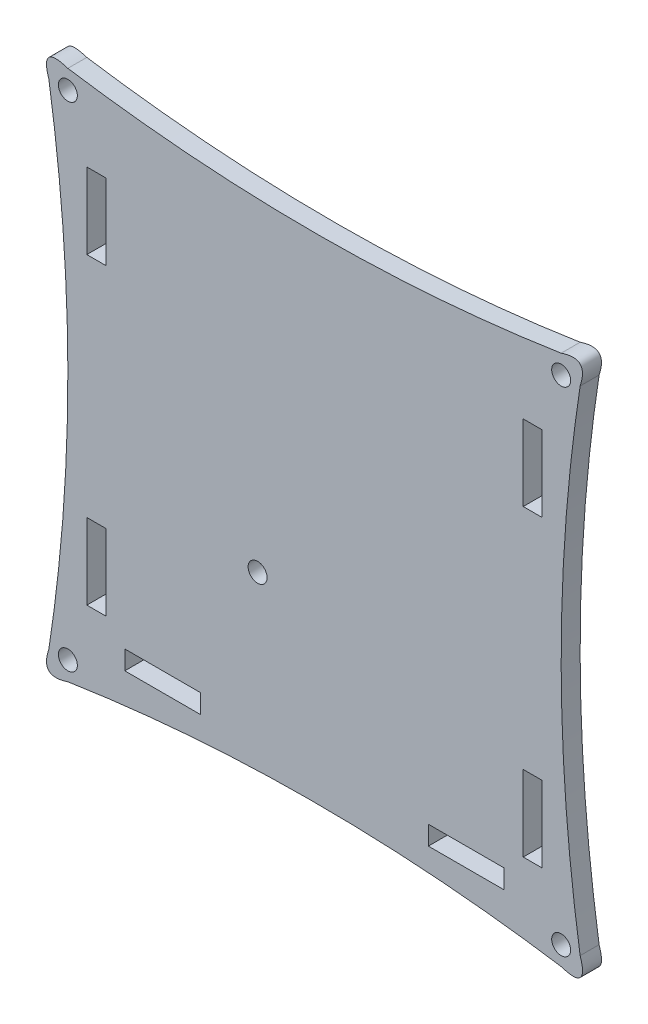
from build123d import *

# Parameters (mm, degrees)
SKETCH1_W           = 6.35
SKETCH1_H           = 25.4
SKETCH1_W_2         = 25.4
SKETCH1_H_2         = 6.35
BOSS_EXTRUDE1_DEPTH = 6.35
SKETCH2_R           = 3.175
CUT_EXTRUDE1_DEPTH  = 6.35
SKETCH3_R           = 3.175
CUT_EXTRUDE2_DEPTH  = 6.35


with BuildPart() as part:
    # Sketch1 → Boss-Extrude1 (new body)
    with BuildSketch(Plane.XY):
        with BuildLine():
            add(Edge.make_bspline(
                [(0, 171.45), (12.7, 88.9), (0, 6.35)],
                knots=[0, 0, 0, 1, 1, 1], degree=2))
            add(Edge.make_bspline(
                [(0, 6.35), (-3.175, -3.175), (6.35, 0)],
                knots=[0, 0, 0, 1, 1, 1], degree=2))
            add(Edge.make_bspline(
                [(6.35, 0), (88.9, 12.7), (171.45, 0)],
                knots=[0, 0, 0, 1, 1, 1], degree=2))
            add(Edge.make_bspline(
                [(177.8, 6.35), (180.975, -3.175), (171.45, 0)],
                knots=[0, 0, 0, 1, 1, 1], degree=2))
            add(Edge.make_bspline(
                [(177.8, 171.45), (165.1, 88.9), (177.8, 6.35)],
                knots=[0, 0, 0, 1, 1, 1], degree=2))
            add(Edge.make_bspline(
                [(171.45, 177.8), (180.975, 180.975), (177.8, 171.45)],
                knots=[0, 0, 0, 1, 1, 1], degree=2))
            add(Edge.make_bspline(
                [(6.35, 177.8), (88.9, 165.1), (171.45, 177.8)],
                knots=[0, 0, 0, 1, 1, 1], degree=2))
            add(Edge.make_bspline(
                [(0, 171.45), (-3.175, 180.975), (6.35, 177.8)],
                knots=[0, 0, 0, 1, 1, 1], degree=2))
        make_face()
        with Locations((15.875, 38.1)):
            Rectangle(SKETCH1_W, SKETCH1_H, mode=Mode.SUBTRACT)
        with Locations((38.1, 15.875)):
            Rectangle(SKETCH1_W_2, SKETCH1_H_2, mode=Mode.SUBTRACT)
        with Locations((15.875, 139.7)):
            Rectangle(SKETCH1_W, SKETCH1_H, mode=Mode.SUBTRACT)
        with Locations((161.925, 139.7)):
            Rectangle(SKETCH1_W, SKETCH1_H, mode=Mode.SUBTRACT)
        with Locations((139.7, 15.875)):
            Rectangle(SKETCH1_W_2, SKETCH1_H_2, mode=Mode.SUBTRACT)
        with Locations((161.925, 38.1)):
            Rectangle(SKETCH1_W, SKETCH1_H, mode=Mode.SUBTRACT)
    extrude(amount=BOSS_EXTRUDE1_DEPTH)

    # Sketch2 → Cut-Extrude1 (cut)
    with BuildSketch(Plane.XY.offset(6.35)):
        with Locations((69.85, 63.5)):
            Circle(SKETCH2_R)
    extrude(amount=-CUT_EXTRUDE1_DEPTH, mode=Mode.SUBTRACT)

    # Sketch3 → Cut-Extrude2 (cut)
    with BuildSketch(Plane.XY.offset(6.35)):
        with Locations((6.35, 6.35)):
            Circle(SKETCH3_R)
        with Locations((171.45, 6.35)):
            Circle(SKETCH3_R)
        with Locations((171.45, 171.45)):
            Circle(SKETCH3_R)
        with Locations((6.35, 171.45)):
            Circle(SKETCH3_R)
    extrude(amount=-CUT_EXTRUDE2_DEPTH, mode=Mode.SUBTRACT)


solid = part.part
